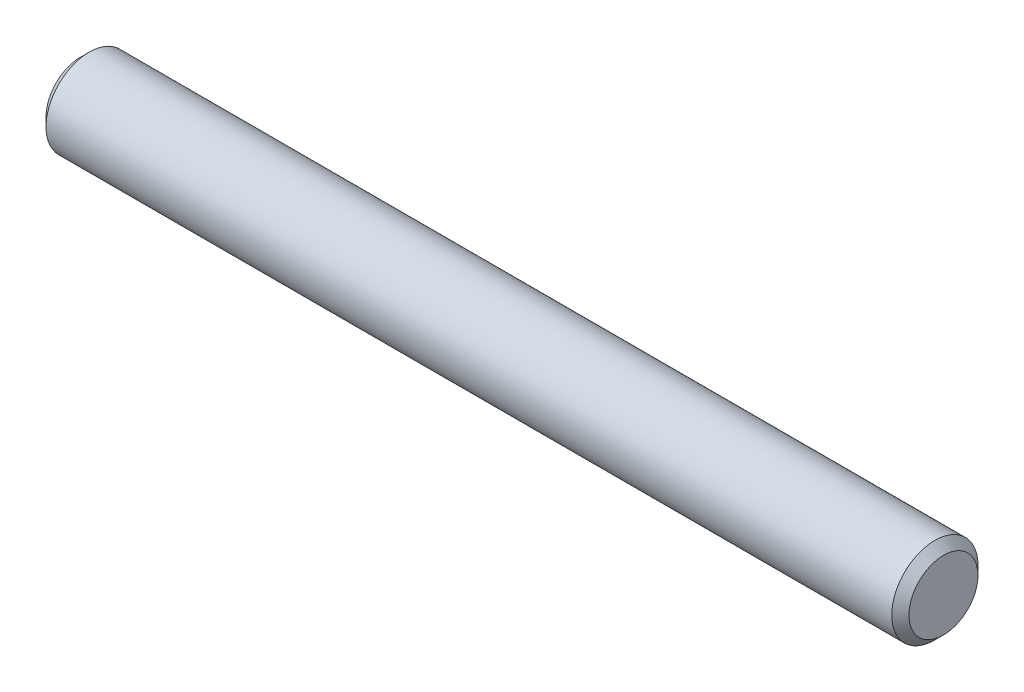
from build123d import *

# Parameters (mm, degrees)
SKETCH2_R           = 1.5875
EXTRUDE1_DEPTH      = 15.875
EXTRUDE1_DEPTH_BACK = 15.875
CHAMFER1_SIZE       = 0.3175


with BuildPart() as part:
    # Sketch2 → Extrude1 (new body, two sides)
    with BuildSketch(Plane(origin=(0, 0, 0), x_dir=(0, 0, -1), z_dir=(1, 0, 0))) as extrude1_sk:
        Circle(SKETCH2_R)
    extrude(amount=EXTRUDE1_DEPTH)
    extrude(extrude1_sk.sketch, amount=-EXTRUDE1_DEPTH_BACK)

    # Chamfer1
    chamfer1_edges = [part.edges().sort_by_distance(p)[0] for p in [
        (-15.875, 0, 1.5875),
        (15.875, 0, 1.5875),
    ]]
    chamfer(chamfer1_edges, length=CHAMFER1_SIZE)


solid = part.part
